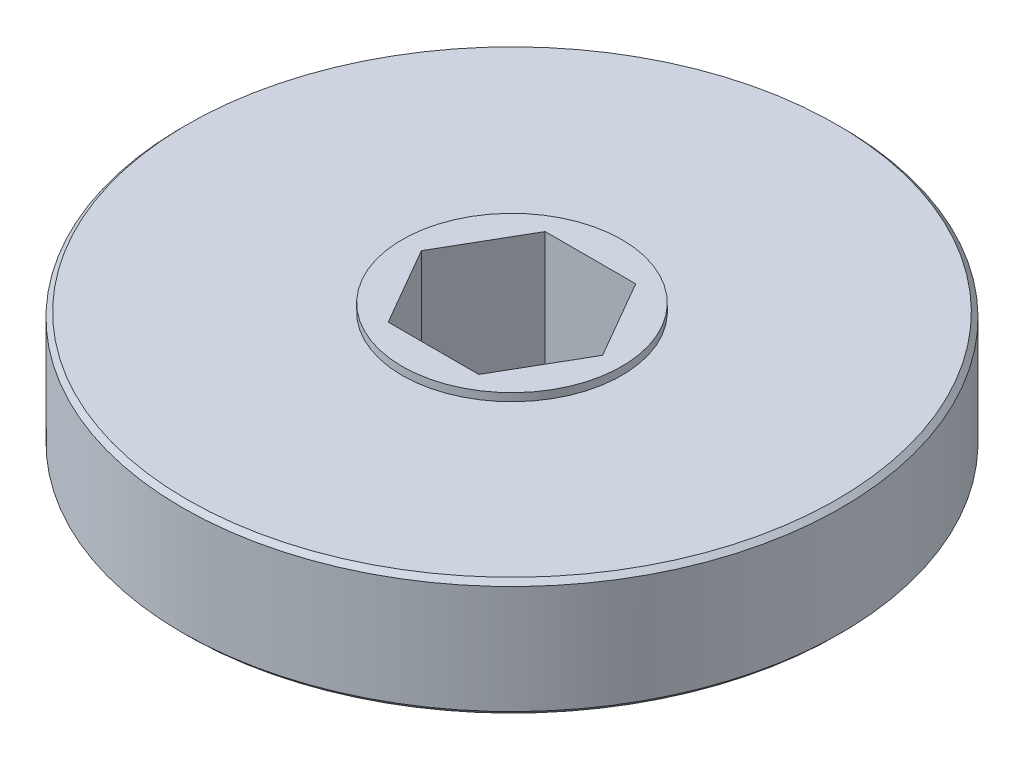
from build123d import *

# Parameters (mm, degrees)
SKETCH1_W           = 26.67
SKETCH1_H           = 9.525
SKETCH2_R           = 8.89
BOSS_EXTRUDE1_DEPTH = 0.635
CUT_EXTRUDE1_DEPTH  = 11.16
CHAMFER1_SIZE       = 0.381


with BuildPart() as part:
    # Sketch1 → Revolve1 (revolve)
    with BuildSketch(Plane(origin=(0, 0, 0), x_dir=(-1, 0, 0), z_dir=(0, 0, -1))):
        with Locations((-13.335, -5.3975)):
            Rectangle(SKETCH1_W, SKETCH1_H)
    revolve(axis=Axis((0, -10.16, 0), (0, 1, 0)))

    # Sketch2 → Boss-Extrude1 (add)
    with BuildSketch(Plane(origin=(0, -0.635, 0), x_dir=(-1, 0, 0), z_dir=(0, 1, 0))):
        Circle(SKETCH2_R)
    extrude(amount=BOSS_EXTRUDE1_DEPTH)

    # Sketch3 → Cut-Extrude1 (cut, through all)
    with BuildSketch(Plane.XZ.offset(10.16)):
        Polygon((-7.332348419, 0), (-3.666174209, -6.35), (3.666174209, -6.35), (7.332348419, 0), (3.666174209, 6.35), (-3.666174209, 6.35), align=None)
    extrude(amount=-CUT_EXTRUDE1_DEPTH, mode=Mode.SUBTRACT)

    # Chamfer1
    chamfer1_edges = [part.edges().sort_by_distance(p)[0] for p in [
        (-26.67, -0.635, 0),
        (-26.67, -10.16, 0),
    ]]
    chamfer(chamfer1_edges, length=CHAMFER1_SIZE)


solid = part.part
